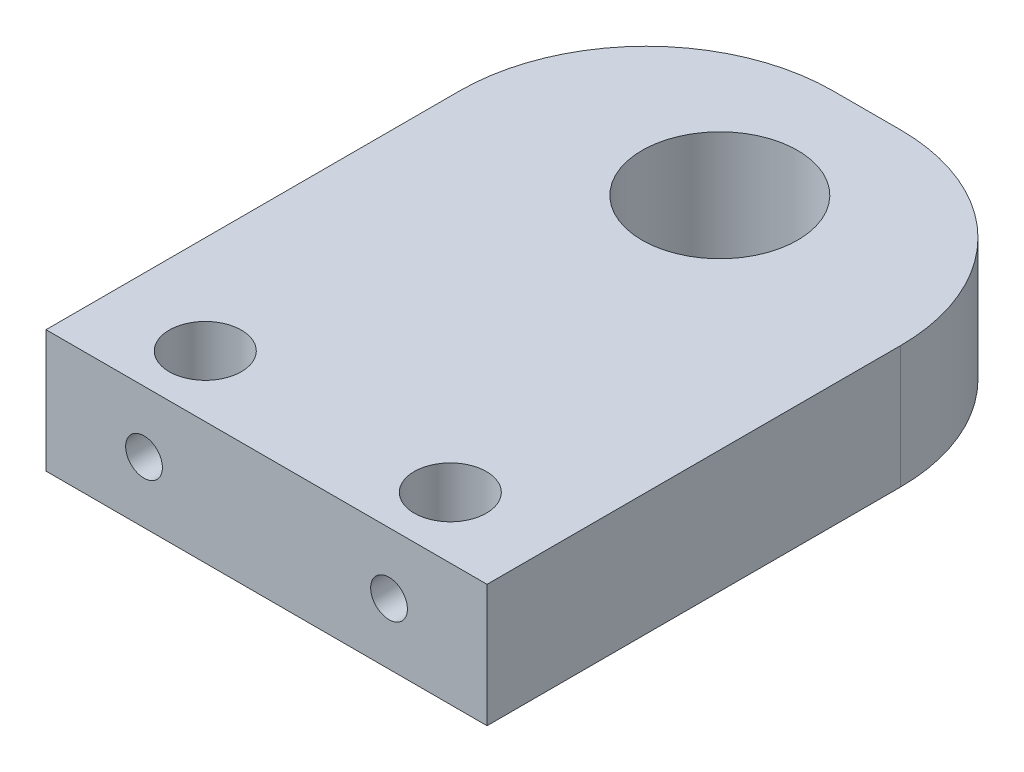
from build123d import *

# Parameters (mm, degrees)
SKETCH1_W                         = 18
SKETCH1_H                         = 24.5
EXTRUDE1_DEPTH                    = 5
SKETCH3_R                         = 1.4732
EXTRUDE2_DEPTH                    = 6
SKETCH4_R                         = 0.75
EXTRUDE3_DEPTH                    = 2.46
FILLET1_R                         = 7.62
F_1_4_20_TAPPED_HOLE1_D           = 5.1054
F_1_4_20_TAPPED_HOLE1_DEPTH       = 16.51
F_1_4_20_TAPPED_HOLE1_CBORE_D     = 6.35
F_1_4_20_TAPPED_HOLE1_CBORE_DEPTH = 12.7
F_1_4_20_TAPPED_HOLE1_TIP         = 1.533816902


with BuildPart() as part:
    # Sketch1 → Extrude1 (new body)
    with BuildSketch(Plane(origin=(0, 0, 0), x_dir=(1, 0, 0), z_dir=(0, 1, 0))):
        with Locations((-9, 12.25)):
            Rectangle(SKETCH1_W, SKETCH1_H)
    extrude(amount=EXTRUDE1_DEPTH)

    # Sketch3 → Extrude2 (cut, through all)
    with BuildSketch(Plane(origin=(0, 5, 0), x_dir=(1, 0, 0), z_dir=(0, 1, 0))):
        with Locations(Location((-14, 2.5, 0), (0, 0, 270))):  # turned: the seam where the file's is
            Circle(SKETCH3_R)
    extrude2 = extrude(amount=-EXTRUDE2_DEPTH, mode=Mode.SUBTRACT)

    # Sketch4 → Extrude3 (cut)
    with BuildSketch(Plane.XY):
        with Locations((-14, 2.5)):
            Circle(SKETCH4_R)
    extrude3 = extrude(amount=-EXTRUDE3_DEPTH, mode=Mode.SUBTRACT)

    # Mirror1: Extrude2, Extrude3 across plane
    add(extrude2.mirror(Plane(origin=(-9, 0, 0), x_dir=(0, 0, 1), z_dir=(1, 0, 0))), mode=Mode.SUBTRACT)
    add(extrude3.mirror(Plane(origin=(-9, 0, 0), x_dir=(0, 0, 1), z_dir=(1, 0, 0))), mode=Mode.SUBTRACT)

    # Fillet1
    fillet1_edges = [part.edges().sort_by_distance(p)[0] for p in [
        (-18, 2.5, -24.5),
        (0, 2.5, -24.5),
    ]]
    fillet(fillet1_edges, radius=FILLET1_R)

    # 1/4-20 Tapped Hole1
    with Locations(Plane(origin=(-9, 5, -18.5), x_dir=(0, 0, 1), z_dir=(0, 1, 0))):
        with Locations((0, 0)):
            CounterBoreHole(F_1_4_20_TAPPED_HOLE1_D / 2, F_1_4_20_TAPPED_HOLE1_CBORE_D / 2, F_1_4_20_TAPPED_HOLE1_CBORE_DEPTH, depth=F_1_4_20_TAPPED_HOLE1_DEPTH)
            with Locations((0, 0, -(F_1_4_20_TAPPED_HOLE1_DEPTH + F_1_4_20_TAPPED_HOLE1_TIP / 2))):  # 118° drill point
                Cone(0, F_1_4_20_TAPPED_HOLE1_D / 2, F_1_4_20_TAPPED_HOLE1_TIP, mode=Mode.SUBTRACT)


solid = part.part
